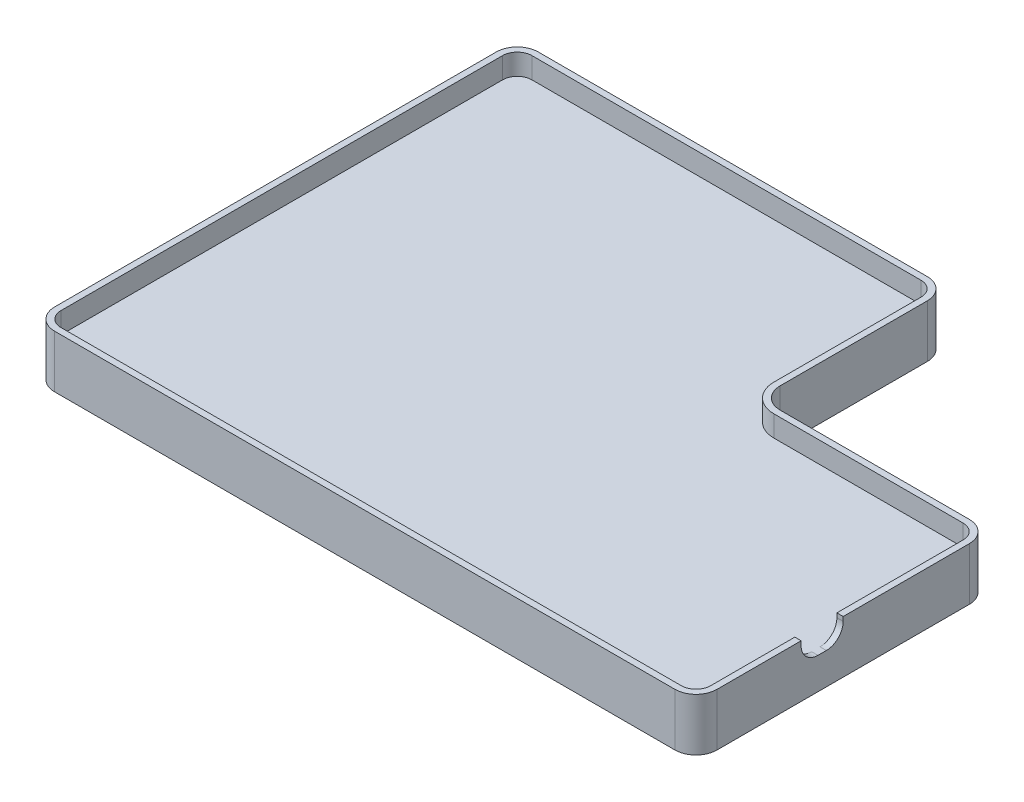
from build123d import *

# Parameters (mm, degrees)
BOSS_EXTRUDE1_DEPTH      = 5
BOSS_EXTRUDE2_DEPTH      = 15
BOSS_EXTRUDE2_DEPTH_BACK = 10
CUT_EXTRUDE1_DEPTH       = 10
FILLET1_R                = 5


with BuildPart() as part:
    # Sketch1 → Boss-Extrude1 (new body)
    with BuildSketch(Plane(origin=(0, 0, 0), x_dir=(1, 0, 0), z_dir=(0, 1, 0))):
        with BuildLine():
            Line((305, 140), (215, 140))
            ThreePointArc((215, 140), (207.928932188, 142.928932188), (205, 150))
            Line((205, 150), (205, 220))
            ThreePointArc((205, 220), (202.071067812, 227.071067812), (195, 230))
            Line((195, 230), (10, 230))
            ThreePointArc((10, 230), (2.928932188, 227.071067812), (0, 220))
            Line((0, 220), (0, 10))
            ThreePointArc((0, 10), (2.928932188, 2.928932188), (10, 0))
            Line((10, 0), (305, 0))
            ThreePointArc((305, 0), (312.071067812, 2.928932188), (315, 10))
            Line((315, 10), (315, 130))
            ThreePointArc((315, 130), (312.071067812, 137.071067812), (305, 140))
        make_face()
    extrude(amount=BOSS_EXTRUDE1_DEPTH)

    # Sketch3 → Boss-Extrude2 (add, two sides)
    with BuildSketch(Plane(origin=(0, 0, 0), x_dir=(1, 0, 0), z_dir=(0, 1, 0))) as boss_extrude2_sk:
        with BuildLine():
            Line((10, 0), (305, 0))
            ThreePointArc((305, 0), (312.071067812, 2.928932188), (315, 10))
            Line((315, 10), (315, 130))
            ThreePointArc((315, 130), (312.071067812, 137.071067812), (305, 140))
            Line((305, 140), (215, 140))
            ThreePointArc((215, 140), (207.928932188, 142.928932188), (205, 150))
            Line((205, 150), (205, 220))
            ThreePointArc((205, 220), (202.071067812, 227.071067812), (195, 230))
            Line((195, 230), (10, 230))
            ThreePointArc((10, 230), (2.928932188, 227.071067812), (0, 220))
            Line((0, 220), (0, 10))
            ThreePointArc((0, 10), (2.928932188, 2.928932188), (10, 0))
        make_face()
        with BuildLine():
            Line((10, 3), (305, 3))
            ThreePointArc((305, 3), (309.949747468, 5.050252532), (312, 10))
            Line((312, 10), (312, 130))
            ThreePointArc((312, 130), (309.949747468, 134.949747468), (305, 137))
            Line((305, 137), (215, 137))
            ThreePointArc((215, 137), (205.807611845, 140.807611845), (202, 150))
            Line((202, 150), (202, 220))
            ThreePointArc((202, 220), (199.949747468, 224.949747468), (195, 227))
            Line((195, 227), (10, 227))
            ThreePointArc((10, 227), (5.050252532, 224.949747468), (3, 220))
            Line((3, 220), (3, 10))
            ThreePointArc((3, 10), (5.050252532, 5.050252532), (10, 3))
        make_face(mode=Mode.SUBTRACT)
    extrude(amount=BOSS_EXTRUDE2_DEPTH)
    extrude(boss_extrude2_sk.sketch, amount=-BOSS_EXTRUDE2_DEPTH_BACK)

    # Sketch4 → Cut-Extrude1 (cut)
    with BuildSketch(Plane(origin=(315, 0, 0), x_dir=(0, 0, -1), z_dir=(1, 0, 0))):
        with BuildLine():
            Line((50, 15), (50, 13))
            ThreePointArc((50, 13), (52.343145751, 7.343145751), (58, 5))
            Line((58, 5), (62, 5))
            ThreePointArc((62, 5), (67.656854249, 7.343145751), (70, 13))
            Line((70, 13), (70, 15))
            Line((70, 15), (50, 15))
        make_face()
    extrude(amount=-CUT_EXTRUDE1_DEPTH, mode=Mode.SUBTRACT)

    # Fillet1
    fillet1_edges = [part.edges().sort_by_distance(p)[0] for p in [
        (157.5, 0, -3),
        (309.949747468, 0, -5.050252532),
        (312, 0, -70),
        (309.949747468, 0, -134.949747468),
        (260, 0, -137),
        (205.807611845, 0, -140.807611845),
        (202, 0, -185),
        (199.949747468, 0, -224.949747468),
        (102.5, 0, -227),
        (5.050252532, 0, -224.949747468),
        (3, 0, -115),
        (5.050252532, 0, -5.050252532),
    ]]
    fillet(fillet1_edges, radius=FILLET1_R)


solid = part.part
